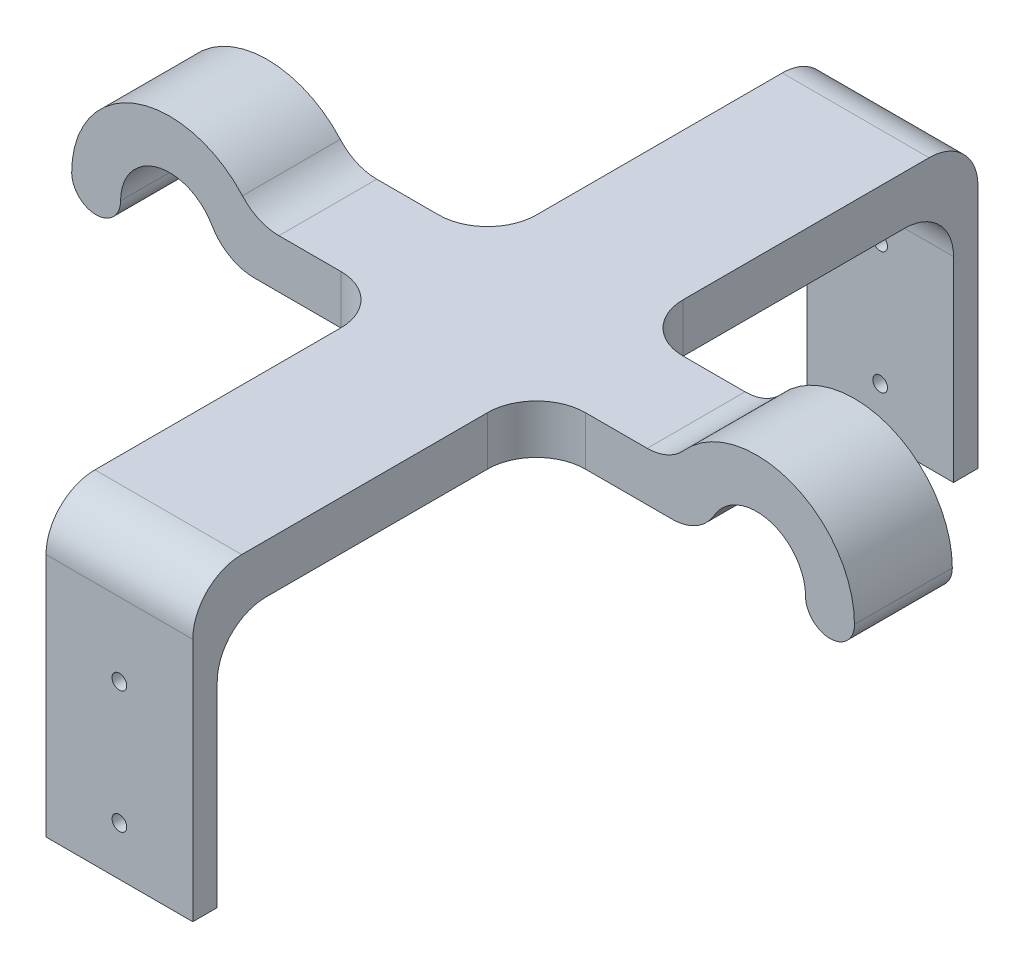
from build123d import *

# Parameters (mm, degrees)
BOSS_EXTRUDE1_DEPTH     = 10
SKETCH2_W               = 30
SKETCH2_H               = 160.5
BOSS_EXTRUDE2_DEPTH     = 10
SKETCH3_W               = 30
SKETCH3_H               = 5
BOSS_EXTRUDE3_DEPTH     = 50
SKETCH4_R               = 1.5
CUT_EXTRUDE1_DEPTH      = 1
CUT_EXTRUDE1_DEPTH_BACK = 161.5
FILLET1_R               = 10
FILLET2_R               = 10
FILLET3_R               = 10


with BuildPart() as part:
    # Sketch1 → Boss-Extrude1 (new body, symmetric)
    with BuildSketch(Plane.XY):
        with BuildLine():
            ThreePointArc((-70, 0), (-60, 10), (-50, 0))
            Line((-50, 0), (-40, 0))
            ThreePointArc((-40, 0), (-40.681483474, 5.176380902), (-42.679491924, 10))
            ThreePointArc((-42.679491924, 10), (-65.176380902, 19.318516526), (-80, 0))
            ThreePointArc((-80, 0), (-75, -5), (-70, 0))
        make_face()
        with BuildLine():
            ThreePointArc((-42.679491924, 10), (-40.681483474, 5.176380902), (-40, 0))
            Line((-40, 0), (40, 0))
            ThreePointArc((40, 0), (40.681483474, 5.176380902), (42.679491924, 10))
            Line((42.679491924, 10), (-42.679491924, 10))
        make_face()
        with BuildLine():
            ThreePointArc((42.679491924, 10), (40.681483474, 5.176380902), (40, 0))
            Line((40, 0), (50, 0))
            ThreePointArc((50, 0), (60, 10), (70, 0))
            ThreePointArc((70, 0), (75, -5), (80, 0))
            ThreePointArc((80, 0), (65.176380902, 19.318516526), (42.679491924, 10))
        make_face()
    extrude(amount=BOSS_EXTRUDE1_DEPTH, both=True)

    # Sketch2 → Boss-Extrude2 (add)
    with BuildSketch(Plane.XZ):
        Rectangle(SKETCH2_W, SKETCH2_H)
    extrude(amount=-BOSS_EXTRUDE2_DEPTH)

    # Sketch3 → Boss-Extrude3 (add)
    with BuildSketch(Plane.XZ):
        with Locations((0, 77.75)):
            Rectangle(SKETCH3_W, SKETCH3_H)
    boss_extrude3 = extrude(amount=BOSS_EXTRUDE3_DEPTH)

    # Mirror1: Boss-Extrude3 across plane
    add(boss_extrude3.mirror(Plane.XY))

    # Sketch4 → Cut-Extrude1 (cut, two sides)
    with BuildSketch(Plane.XY.offset(80.25)) as cut_extrude1_sk:
        with Locations((0, -40)):
            Circle(SKETCH4_R)
        with Locations((0, -15)):
            Circle(SKETCH4_R)
    extrude(amount=CUT_EXTRUDE1_DEPTH, mode=Mode.SUBTRACT)
    extrude(cut_extrude1_sk.sketch, amount=-CUT_EXTRUDE1_DEPTH_BACK, mode=Mode.SUBTRACT)

    # Fillet1
    fillet1_edges = [part.edges().sort_by_distance(p)[0] for p in [
        (0, 10, -80.25),
        (0, 10, 80.25),
        (0, 0, 75.25),
        (0, 0, -75.25),
    ]]
    fillet(fillet1_edges, radius=FILLET1_R)

    # Fillet2
    fillet2_edges = [part.edges().sort_by_distance(p)[0] for p in [
        (-15, 5, -10),
        (15, 5, -10),
        (15, 5, 10),
        (-15, 5, 10),
    ]]
    fillet(fillet2_edges, radius=FILLET2_R)

    # Fillet3
    fillet3_edges = [part.edges().sort_by_distance(p)[0] for p in [
        (-42.679491924, 10, 0),
        (42.679491924, 10, 0),
        (50, 0, 0),
        (-50, 0, 0),
    ]]
    fillet(fillet3_edges, radius=FILLET3_R)


solid = part.part
